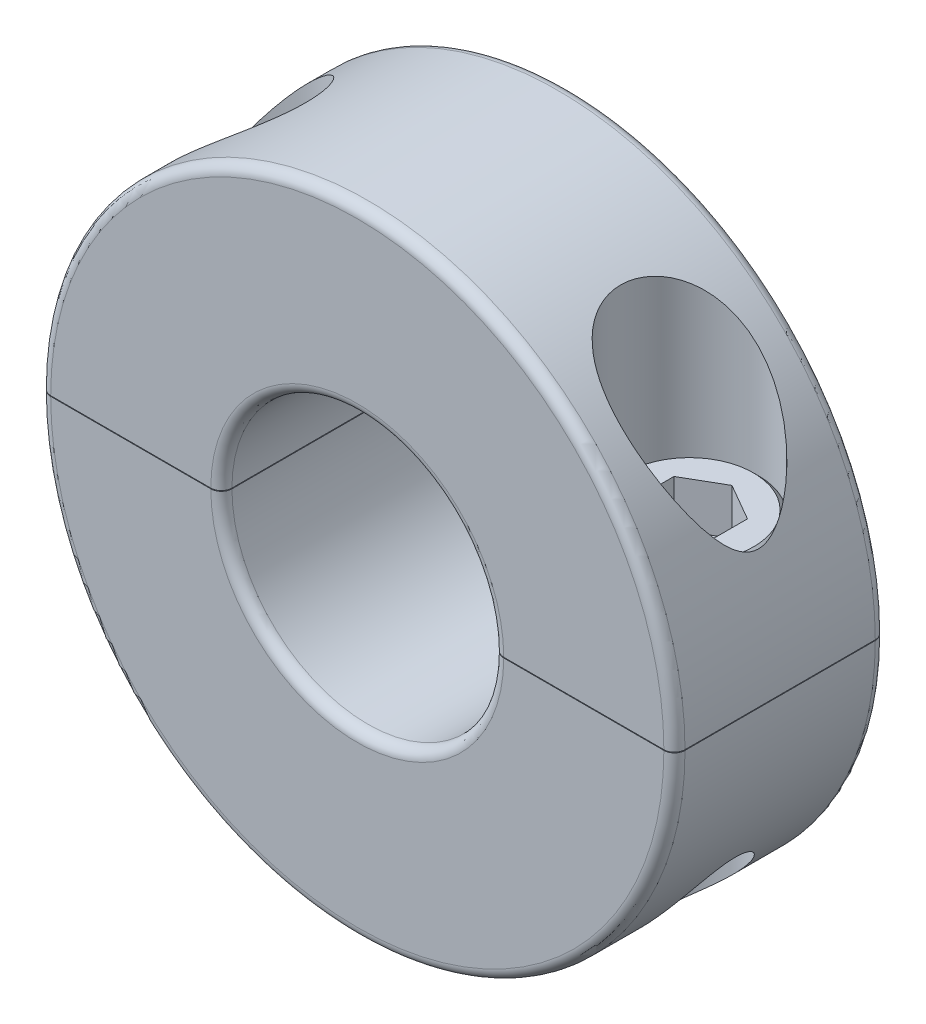
from build123d import *

# Parameters (mm, degrees)
EXTRUDE1_DEPTH     = 5.55625
EXTRUDE1_2_DEPTH   = 5.55625
CUT_EXTRUDE2_DEPTH = 2.413
FILLET1_R          = 0.555625
FILLET2_R          = 0.555625
CHAMFER1_SIZE      = 0.254
CHAMFER2_SIZE      = 0.254


with BuildPart() as part:
    # Sketch1 → Extrude1 (new body, symmetric)
    with BuildSketch(Plane.XY):
        with BuildLine():
            Line((-16.66875, 0.01666875), (-7.14375, 0.01666875))
            ThreePointArc((-7.14375, 0.01666875), (0, 7.16041875), (7.14375, 0.01666875))
            Line((7.14375, 0.01666875), (16.66875, 0.01666875))
            ThreePointArc((16.66875, 0.01666875), (0, 16.68541875), (-16.66875, 0.01666875))
        make_face()
    extrude(amount=EXTRUDE1_DEPTH, both=True)


with BuildPart() as body_2:
    # Sketch1 → Extrude1 2 (new body, symmetric)
    with BuildSketch(Plane.XY):
        with BuildLine():
            Line((-16.66875, -0.01666875), (-7.14375, -0.01666875))
            ThreePointArc((-7.14375, -0.01666875), (0, -7.16041875), (7.14375, -0.01666875))
            Line((7.14375, -0.01666875), (16.66875, -0.01666875))
            ThreePointArc((16.66875, -0.01666875), (0, -16.68541875), (-16.66875, -0.01666875))
        make_face()
    extrude(amount=EXTRUDE1_2_DEPTH, both=True)


with BuildPart() as cut_revolve1_tool:
    # Sketch4 → Cut-Revolve1 (revolve)
    with BuildSketch(Plane.XY):
        Polygon((-11.90625, 16.68541875), (-8.28675, 16.68541875), (-8.28675, 1.22316875), (-9.49325, 1.22316875), (-9.49325, -16.68541875), (-11.90625, -16.68541875), align=None)
    cut_revolve1 = revolve(axis=Axis((-11.90625, -16.68541875, 0), (0, 1, 0)))


with BuildPart() as part_1:
    add(part.part)

    # Cut-Revolve1: cut by cut_revolve1_tool
    add(cut_revolve1_tool.part, mode=Mode.SUBTRACT)


with BuildPart() as body_2_1:
    add(body_2.part)

    # Cut-Revolve1: cut by cut_revolve1_tool
    add(cut_revolve1_tool.part, mode=Mode.SUBTRACT)


with BuildPart() as body_3:
    # Sketch6 → Revolve1 (revolve)
    with BuildSketch(Plane.XY):
        Polygon((-11.90625, 6.04916875), (-8.28675, 6.04916875), (-8.28675, 1.22316875), (-9.49325, 1.22316875), (-9.49325, -8.42883125), (-11.90625, -8.42883125), align=None)
    revolve(axis=Axis((-11.90625, -8.42883125, 0), (0, 1, 0)))

    # Sketch7 → Cut-Extrude2 (cut)
    with BuildSketch(Plane(origin=(0, 6.04916875, 0), x_dir=(-1, 0, 0), z_dir=(0, 1, 0))):
        Polygon((11.90625, -2.229033919), (13.83665, -1.11451696), (13.83665, 1.11451696), (11.90625, 2.229033919), (9.97585, 1.11451696), (9.97585, -1.11451696), align=None)
    extrude(amount=-CUT_EXTRUDE2_DEPTH, mode=Mode.SUBTRACT)


with BuildPart() as mirror1_tool:
    # Mirror1: Cut-Revolve1 across plane
    add(cut_revolve1.mirror(Plane(origin=(0, 0, 0), x_dir=(0, 0, 1), z_dir=(1, 0, 0))))


with BuildPart() as part_2:
    add(part_1.part)

    # Mirror1: cut by mirror1_tool
    add(mirror1_tool.part, mode=Mode.SUBTRACT)

    # Fillet1
    fillet1_edges = [part_2.edges().sort_by_distance(p)[0] for p in [
        (0, 7.16041875, 5.55625),
        (0, 16.68541875, 5.55625),
        (0, 7.16041875, -5.55625),
        (0, 16.68541875, -5.55625),
    ]]
    fillet(fillet1_edges, radius=FILLET1_R)


with BuildPart() as body_2_2:
    add(body_2_1.part)

    # Mirror1: cut by mirror1_tool
    add(mirror1_tool.part, mode=Mode.SUBTRACT)

    # Fillet2
    fillet2_edges = [body_2_2.edges().sort_by_distance(p)[0] for p in [
        (0, -7.16041875, 5.55625),
        (0, -16.68541875, 5.55625),
        (0, -7.16041875, -5.55625),
        (0, -16.68541875, -5.55625),
    ]]
    fillet(fillet2_edges, radius=FILLET2_R)


with BuildPart() as body_4:
    # Mirror2: mirrored copy
    add(body_3.part.mirror(Plane(origin=(0, 0, 0), x_dir=(0, 0, 1), z_dir=(1, 0, 0))))

    # Chamfer1
    chamfer1_edges = [body_4.edges().sort_by_distance(p)[0] for p in [
        (15.52575, 6.04916875, 0),
    ]]
    chamfer(chamfer1_edges, length=CHAMFER1_SIZE)


with BuildPart() as body_3_1:
    add(body_3.part)

    # Chamfer2
    chamfer2_edges = [body_3_1.edges().sort_by_distance(p)[0] for p in [
        (-15.52575, 6.04916875, 0),
    ]]
    chamfer(chamfer2_edges, length=CHAMFER2_SIZE)


solid = Compound([part_2.part, body_2_2.part, body_4.part, body_3_1.part])
